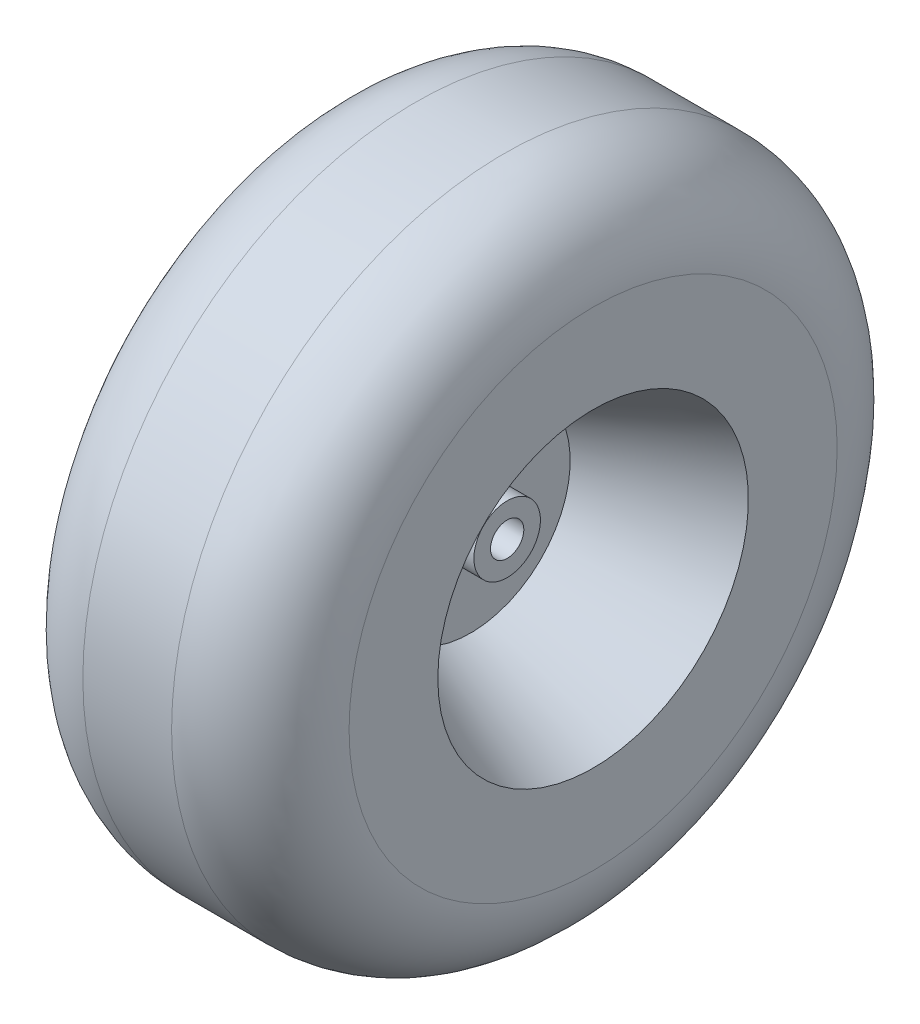
from build123d import *


with BuildPart() as part:
    # Sketch1 → Revolve1 (revolve)
    with BuildSketch(Plane.XY):
        with BuildLine():
            Line((-26.9875, 9.525), (26.9875, 9.525))
            Line((26.9875, 9.525), (26.9875, 19.05))
            Line((26.9875, 19.05), (6.112639692, 19.05))
            Line((6.112639692, 19.05), (6.112639692, 56.974587415))
            Line((6.112639692, 56.974587415), (76.2, 88.9))
            Line((76.2, 88.9), (76.2, 139.7))
            ThreePointArc((76.2, 139.7), (61.321024484, 175.621024484), (25.4, 190.5))
            Line((25.4, 190.5), (-25.4, 190.5))
            ThreePointArc((-25.4, 190.5), (-61.321024484, 175.621024484), (-76.2, 139.7))
            Line((-76.2, 139.7), (-76.2, 88.9))
            Line((-76.2, 88.9), (-6.112639692, 56.974587415))
            Line((-6.112639692, 56.974587415), (-6.112639692, 19.05))
            Line((-6.112639692, 19.05), (-26.9875, 19.05))
            Line((-26.9875, 19.05), (-26.9875, 9.525))
        make_face()
    revolve(axis=Axis((-76.2, 0, 0), (1, 0, 0)))


solid = part.part
